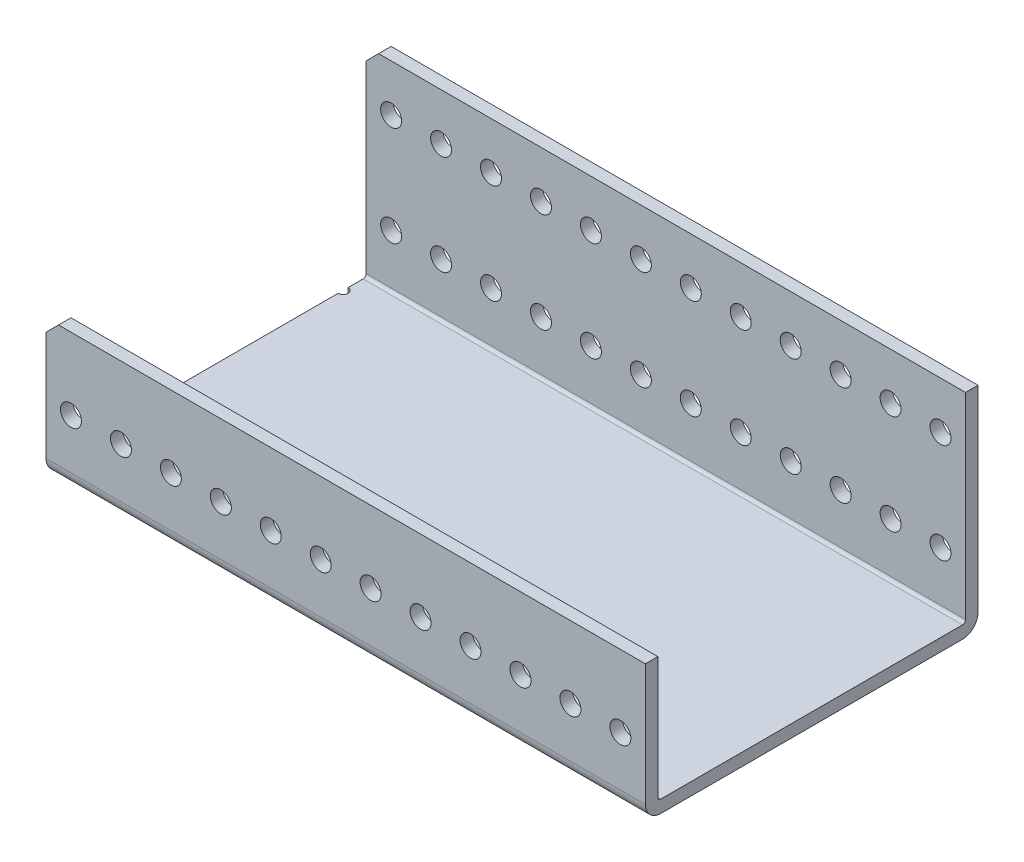
from build123d import *

# Parameters (mm, degrees)
SKETCH1_W            = 698.5
SKETCH1_H            = 84.582
BOSS_EXTRUDE1_DEPTH  = 34.925
SKETCH2_W            = 81.407
SKETCH2_H            = 31.75
CUT_EXTRUDE1_DEPTH   = 699.5
SKETCH3_W            = 698.5
SKETCH3_H            = 3.175
BOSS_EXTRUDE2_DEPTH  = 50.8
M2_CLEARANCE_HOLE1_D = 2.54
M5_CLEARANCE_HOLE1_D = 5.334
CHAMFER1_SIZE        = 3.175
FILLET1_R            = 0.762
FILLET2_R            = 3.937
SKETCH8_W            = 848.789904452
SKETCH8_H            = 432.95839962
CUT_EXTRUDE2_DEPTH   = 85.582


with BuildPart() as part:
    # Sketch1 → Boss-Extrude1 (new body)
    with BuildSketch(Plane(origin=(0, 57.816398039, 0), x_dir=(1, 0, 0), z_dir=(0, 1, 0))):
        with Locations((253.148031467, -103.269491579)):
            Rectangle(SKETCH1_W, SKETCH1_H)
    extrude(amount=-BOSS_EXTRUDE1_DEPTH)

    # Sketch2 → Cut-Extrude1 (cut, through all)
    with BuildSketch(Plane(origin=(602.398031467, 0, 0), x_dir=(0, 0, -1), z_dir=(1, 0, 0))):
        with Locations((-101.681991579, 41.941398039)):
            Rectangle(SKETCH2_W, SKETCH2_H)
    extrude(amount=-CUT_EXTRUDE1_DEPTH, mode=Mode.SUBTRACT)

    # Sketch3 → Boss-Extrude2 (add)
    with BuildSketch(Plane(origin=(0, 26.066398039, 0), x_dir=(-1, 0, 0), z_dir=(0, 1, 0))):
        with Locations((-253.148031467, 62.565991579)):
            Rectangle(SKETCH3_W, SKETCH3_H)
    extrude(amount=BOSS_EXTRUDE2_DEPTH)

    # M2 Clearance Hole1 (through all)
    with Locations(Plane(origin=(0, 26.066398039, 0), x_dir=(1, 0, 0), z_dir=(0, 1, 0))):
        with Locations((-96.101968533, -136.543491579), (-96.101968533, -69.995491579)):
            Hole(M2_CLEARANCE_HOLE1_D / 2)

    # M5 Clearance Hole1 (through all)
    with Locations(Plane(origin=(0, 0, 60.978491579), x_dir=(-1, 0, 0), z_dir=(0, 0, -1))):
        with Locations((-469.048031467, 64.928398039), (-481.748031467, 64.928398039), (-469.048031467, 39.528398039), (-481.748031467, 39.528398039), (-456.348031467, 39.528398039), (-443.648031467, 39.528398039), (-430.948031467, 39.528398039), (-418.248031467, 39.528398039), (-405.548031467, 39.528398039), (-392.848031467, 39.528398039), (-380.148031467, 39.528398039), (-367.448031467, 39.528398039), (-354.748031467, 39.528398039), (-342.048031467, 39.528398039), (-329.348031467, 39.528398039), (-316.648031467, 39.528398039), (-303.948031467, 39.528398039), (-291.248031467, 39.528398039), (-278.548031467, 39.528398039), (-265.848031467, 39.528398039), (-253.148031467, 39.528398039), (-240.448031467, 39.528398039), (-227.748031467, 39.528398039), (-215.048031467, 39.528398039), (-202.348031467, 39.528398039), (-189.648031467, 39.528398039), (-176.948031467, 39.528398039), (-164.248031467, 39.528398039), (-151.548031467, 39.528398039), (-138.848031467, 39.528398039), (-126.148031467, 39.528398039), (-113.448031467, 39.528398039), (-100.748031467, 39.528398039), (-88.048031467, 39.528398039), (-75.348031467, 39.528398039), (-62.648031467, 39.528398039), (-49.948031467, 39.528398039), (-37.248031467, 39.528398039), (-24.548031467, 39.528398039), (-11.848031467, 39.528398039), (0.851968533, 39.528398039), (13.551968533, 39.528398039), (26.251968533, 39.528398039), (38.951968533, 39.528398039), (51.651968533, 39.528398039), (64.351968533, 39.528398039), (77.051968533, 39.528398039), (89.751968533, 39.528398039), (-456.348031467, 64.928398039), (-443.648031467, 64.928398039), (-430.948031467, 64.928398039), (-418.248031467, 64.928398039), (-405.548031467, 64.928398039), (-392.848031467, 64.928398039), (-380.148031467, 64.928398039), (-367.448031467, 64.928398039), (-354.748031467, 64.928398039), (-342.048031467, 64.928398039), (-329.348031467, 64.928398039), (-316.648031467, 64.928398039), (-303.948031467, 64.928398039), (-291.248031467, 64.928398039), (-278.548031467, 64.928398039), (-265.848031467, 64.928398039), (-253.148031467, 64.928398039), (-240.448031467, 64.928398039), (-227.748031467, 64.928398039), (-215.048031467, 64.928398039), (-202.348031467, 64.928398039), (-189.648031467, 64.928398039), (-176.948031467, 64.928398039), (-164.248031467, 64.928398039), (-151.548031467, 64.928398039), (-138.848031467, 64.928398039), (-126.148031467, 64.928398039), (-113.448031467, 64.928398039), (-100.748031467, 64.928398039), (-88.048031467, 64.928398039), (-75.348031467, 64.928398039), (-62.648031467, 64.928398039), (-49.948031467, 64.928398039), (-37.248031467, 64.928398039), (-24.548031467, 64.928398039), (-11.848031467, 64.928398039), (0.851968533, 64.928398039), (13.551968533, 64.928398039), (26.251968533, 64.928398039), (38.951968533, 64.928398039), (51.651968533, 64.928398039), (64.351968533, 64.928398039), (77.051968533, 64.928398039), (89.751968533, 64.928398039), (-494.448031467, 64.928398039), (-494.448031467, 39.528398039), (-507.148031467, 64.928398039), (-507.148031467, 39.528398039), (-519.848031467, 64.928398039), (-519.848031467, 39.528398039), (-532.548031467, 64.928398039), (-532.548031467, 39.528398039), (-545.248031467, 64.928398039), (-545.248031467, 39.528398039), (-557.948031467, 64.928398039), (-557.948031467, 39.528398039), (-570.648031467, 64.928398039), (-570.648031467, 39.528398039), (-583.348031467, 64.928398039), (-583.348031467, 39.528398039), (-596.048031467, 64.928398039), (-596.048031467, 39.528398039)):
            Hole(M5_CLEARANCE_HOLE1_D / 2)

    # Chamfer1
    chamfer1_edges = [part.edges().sort_by_distance(p)[0] for p in [
        (-96.101968533, 57.816398039, 143.972991579),
        (-96.101968533, 76.866398039, 62.565991579),
        (602.398031467, 76.866398039, 62.565991579),
        (602.398031467, 57.816398039, 143.972991579),
    ]]
    chamfer(chamfer1_edges, length=CHAMFER1_SIZE)

    # Fillet1
    fillet1_edges = [part.edges().sort_by_distance(p)[0] for p in [
        (253.148031467, 26.066398039, 142.385491579),
        (253.148031467, 26.066398039, 64.153491579),
    ]]
    fillet(fillet1_edges, radius=FILLET1_R)

    # Fillet2
    fillet2_edges = [part.edges().sort_by_distance(p)[0] for p in [
        (253.148031467, 22.891398039, 60.978491579),
        (253.148031467, 22.891398039, 145.560491579),
    ]]
    fillet(fillet2_edges, radius=FILLET2_R)

    # Sketch8 → Cut-Extrude2 (cut, through all)
    with BuildSketch(Plane(origin=(0, 0, 60.978491579), x_dir=(-1, 0, 0), z_dir=(0, 0, -1))):
        with Locations((-480.692983693, 24.593327381)):
            Rectangle(SKETCH8_W, SKETCH8_H)
    extrude(amount=-CUT_EXTRUDE2_DEPTH, mode=Mode.SUBTRACT)


solid = part.part
